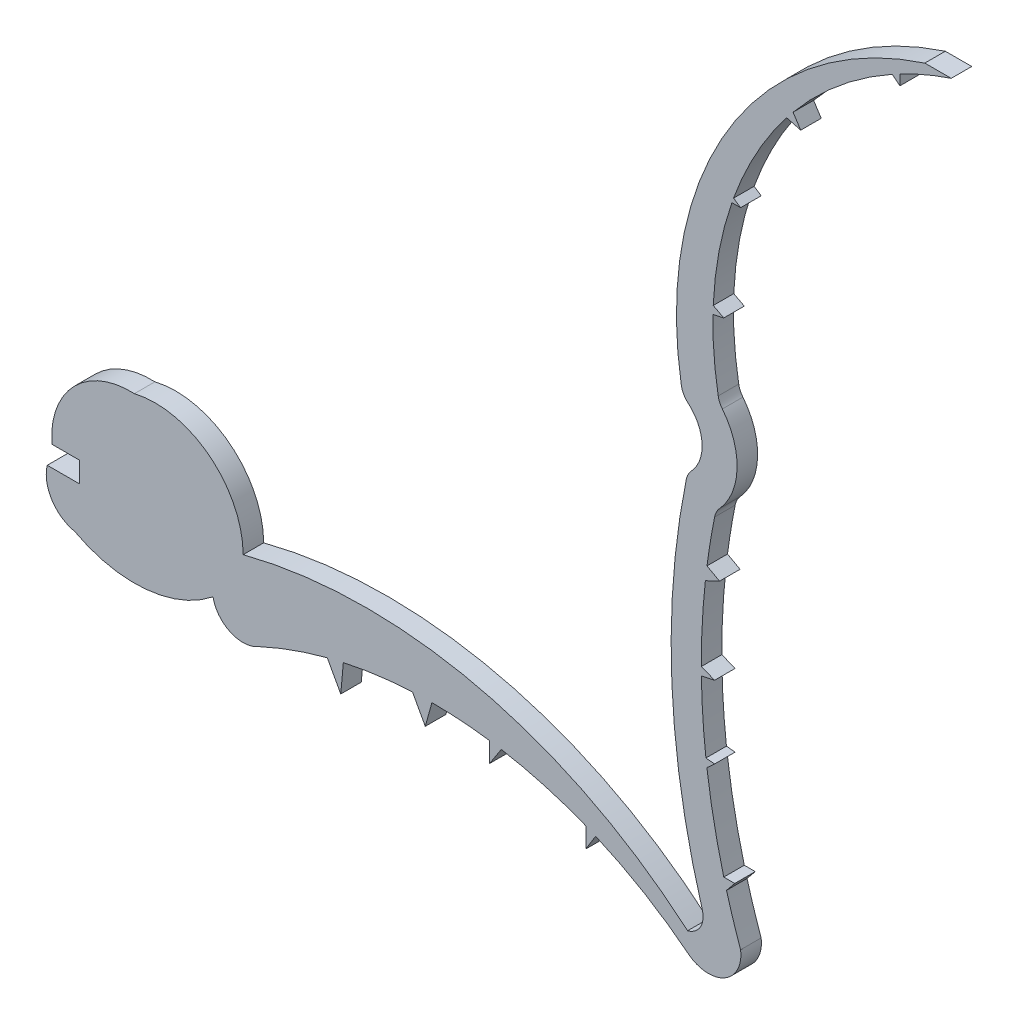
from build123d import *

# Parameters (mm, degrees)
BOSS_EXTRUDE1_DEPTH = 1.524


with BuildPart() as part:
    # Sketch1 → Boss-Extrude1 (new body)
    with BuildSketch(Plane.XY):
        with BuildLine():
            Line((12.801369516, 0), (12.801369516, -1.524))
            Line((12.801369516, -1.524), (10.391932007, -1.524))
            ThreePointArc((10.391932007, -1.524), (10.729282299, -3.576784737), (12.438012127, -4.763365021))
            ThreePointArc((12.438012127, -4.763365021), (17.707377285, -5.836214945), (22.697391826, -3.831976686))
            ThreePointArc((22.697391826, -3.831976686), (24.001804643, -5.463328455), (26.08664711, -5.335918573))
            ThreePointArc((26.08664711, -5.335918573), (28.593778041, -4.308492819), (31.181851225, -3.506503807))
            Line((31.181851225, -3.506503807), (32.184006456, -5.335918573))
            Line((32.184006456, -5.335918573), (32.373708357, -3.219533349))
            ThreePointArc((32.373708357, -3.219533349), (34.925372654, -2.771007765), (37.505800807, -2.53958514))
            Line((37.505800807, -2.53958514), (38.45795608, -4.277725961))
            Line((38.45795608, -4.277725961), (38.950884125, -2.505498906))
            ThreePointArc((38.950884125, -2.505498906), (41.098053648, -2.580802933), (43.234672107, -2.806344974))
            Line((43.234672107, -2.806344974), (43.234672107, -4.277725961))
            Line((43.234672107, -4.277725961), (44.101614036, -2.941400649))
            ThreePointArc((44.101614036, -2.941400649), (47.285508928, -3.660506996), (50.374872797, -4.714134778))
            Line((50.374872797, -4.714134778), (50.374872797, -6.206057494))
            Line((50.374872797, -6.206057494), (51.106289172, -5.018968989))
            ThreePointArc((51.106289172, -5.018968989), (54.742715091, -6.887018604), (58.098173874, -9.222419893))
            ThreePointArc((58.098173874, -9.222419893), (60.731696449, -9.312826177), (61.868627066, -6.935642292))
            ThreePointArc((61.868627066, -6.935642292), (61.317201318, -5.297304696), (60.822209833, -3.641042681))
            Line((60.822209833, -3.641042681), (61.432885238, -2.890340871))
            Line((61.432885238, -2.890340871), (60.618018518, -2.890340871))
            ThreePointArc((60.618018518, -2.890340871), (59.887453188, 0.294487754), (59.364520303, 3.519918))
            Line((59.364520303, 3.519918), (59.938762272, 4.044130938))
            Line((59.938762272, 4.044130938), (59.292703769, 4.103102621))
            ThreePointArc((59.292703769, 4.103102621), (59.05887021, 6.657377407), (58.95511856, 9.220233903))
            Line((58.95511856, 9.220233903), (59.938762272, 9.426656134))
            Line((59.938762272, 9.426656134), (58.949679492, 9.813602305))
            ThreePointArc((58.949679492, 9.813602305), (59.020268562, 12.652910586), (59.250476195, 15.483751235))
            Line((59.250476195, 15.483751235), (60.304285386, 15.979807686))
            Line((60.304285386, 15.979807686), (59.371854232, 16.495625036))
            ThreePointArc((59.371854232, 16.495625036), (59.625803461, 18.214330904), (59.938762272, 19.923277028))
            ThreePointArc((59.938762272, 19.923277028), (60.072497403, 20.30995458), (60.304285386, 20.647117664))
            ThreePointArc((60.304285386, 20.647117664), (61.605742963, 23.863190011), (60.513628087, 27.156243043))
            ThreePointArc((60.513628087, 27.156243043), (60.316413067, 27.479275668), (60.204881845, 27.840944893))
            ThreePointArc((60.204881845, 27.840944893), (59.887129724, 30.355756102), (59.816689824, 32.889583256))
            Line((59.816689824, 32.889583256), (60.618018518, 33.060793415))
            Line((60.618018518, 33.060793415), (59.835472852, 33.469819147))
            ThreePointArc((59.835472852, 33.469819147), (60.265577513, 37.173766341), (61.223023534, 40.77758542))
            Line((61.223023534, 40.77758542), (61.868627066, 40.77758542))
            Line((61.868627066, 40.77758542), (61.345913077, 41.12626446))
            ThreePointArc((61.345913077, 41.12626446), (63.032929734, 44.85342804), (65.285725915, 48.268495084))
            Line((65.285725915, 48.268495084), (66.32927785, 47.988149788))
            Line((66.32927785, 47.988149788), (65.763533096, 48.863100705))
            ThreePointArc((65.763533096, 48.863100705), (69.158811096, 52.264251778), (73.1239346, 54.979677512))
            Line((73.1239346, 54.979677512), (73.693442296, 54.520997073))
            Line((73.693442296, 54.520997073), (73.693442296, 55.287173458))
            ThreePointArc((73.693442296, 55.287173458), (75.566961014, 56.175053965), (77.50548515, 56.910260303))
            Line((77.50548515, 56.910260303), (75.543932889, 56.910260303))
            ThreePointArc((75.543932889, 56.910260303), (60.978808558, 45.393240793), (57.46632066, 27.160111223))
            ThreePointArc((57.46632066, 27.160111223), (57.643802358, 26.659339703), (57.982404007, 26.24992452))
            ThreePointArc((57.982404007, 26.24992452), (59.006767547, 24.18711185), (58.217688211, 22.023348792))
            ThreePointArc((58.217688211, 22.023348792), (57.974404382, 21.680039515), (57.834272182, 21.283288652))
            ThreePointArc((57.834272182, 21.283288652), (56.763038041, 7.682552112), (59.02088406, -5.772175992))
            ThreePointArc((59.02088406, -5.772175992), (58.884555424, -6.959716199), (57.933337254, -7.683609307))
            ThreePointArc((57.933337254, -7.683609307), (42.379716063, 0.214147761), (24.937129111, 0))
            ThreePointArc((24.937129111, 0), (22.427681087, 5.112001973), (16.861199629, 6.313741433))
            ThreePointArc((16.861199629, 6.313741433), (12.668346736, 4.819065663), (10.729282299, 0.812308851))
            Line((10.729282299, 0.812308851), (10.729282299, 0))
            Line((10.729282299, 0), (12.801369516, 0))
        make_face()
    extrude(amount=BOSS_EXTRUDE1_DEPTH)


solid = part.part
